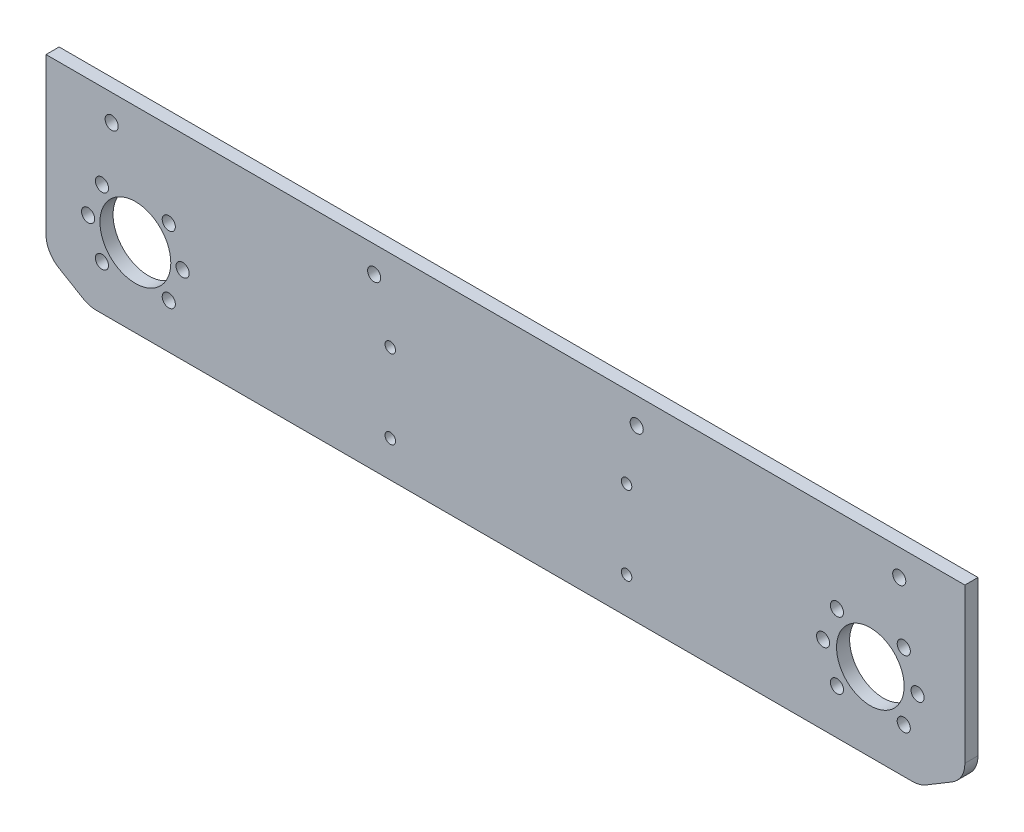
from build123d import *

# Parameters (mm, degrees)
SKETCH_1_R      = 2.5
SKETCH_1_R_2    = 12.875
SKETCH_1_R_3    = 13.5
SKETCH_1_R_4    = 2
EXTRUDE_1_DEPTH = 5


with BuildPart() as part:
    # 草圖1 → 填料-伸長1 (new body)
    with BuildSketch(Plane.XY):
        with BuildLine():
            Line((-177.402767175, 46.597232825), (172.597232825, 46.597232825))
            Line((172.597232825, 46.597232825), (172.597232825, -3.218275341))
            Line((172.597232825, -3.218275341), (172.597232825, -12.212255112))
            ThreePointArc((172.597232825, -12.212255112), (171.299816564, -17.138210478), (167.744225572, -20.785962926))
            Line((167.744225572, -20.785962926), (157.766802923, -26.775637768))
            ThreePointArc((157.766802923, -26.775637768), (155.290289709, -27.838762374), (152.619810177, -28.201929955))
            Line((152.619810177, -28.201929955), (-158.204749101, -28.201929955))
            ThreePointArc((-158.204749101, -28.201929955), (-160.839127997, -27.848693549), (-163.287395186, -26.813939522))
            Line((-163.287395186, -26.813939522), (-172.48541326, -21.385442237))
            ThreePointArc((-172.48541326, -21.385442237), (-176.08684631, -17.731937443), (-177.402767175, -12.77343267))
            Line((-177.402767175, -12.77343267), (-177.402767175, -10.307650594))
            Line((-177.402767175, -10.307650594), (-177.402767175, -3.218275341))
            Line((-177.402767175, -3.218275341), (-177.402767175, 46.597232825))
        make_face()
        with Locations((118.590211239, 1.636058568)):
            Circle(SKETCH_1_R, mode=Mode.SUBTRACT)
        with Locations((154.590211239, 1.636058568)):
            Circle(SKETCH_1_R, mode=Mode.SUBTRACT)
        with Locations((136.590211239, 1.636058568)):
            Circle(SKETCH_1_R_2, mode=Mode.SUBTRACT)
        with Locations((-143.364629919, 1.616144457)):
            Circle(SKETCH_1_R_3, mode=Mode.SUBTRACT)
        with Locations((-130.636707858, 14.344066518)):
            Circle(SKETCH_1_R, mode=Mode.SUBTRACT)
        with Locations((-156.09255198, 14.344066518)):
            Circle(SKETCH_1_R, mode=Mode.SUBTRACT)
        with Locations((-130.636707858, -11.111777604)):
            Circle(SKETCH_1_R, mode=Mode.SUBTRACT)
        with Locations((-156.09255198, -11.111777604)):
            Circle(SKETCH_1_R, mode=Mode.SUBTRACT)
        with Locations((-152.402767175, 36.597232825)):
            Circle(SKETCH_1_R, mode=Mode.SUBTRACT)
        with Locations((-52.402767175, 36.597232825)):
            Circle(SKETCH_1_R, mode=Mode.SUBTRACT)
        with Locations((47.597232825, 36.597232825)):
            Circle(SKETCH_1_R, mode=Mode.SUBTRACT)
        with Locations((147.597232825, 36.597232825)):
            Circle(SKETCH_1_R, mode=Mode.SUBTRACT)
        with Locations((-161.364629919, 1.616144457)):
            Circle(SKETCH_1_R, mode=Mode.SUBTRACT)
        with Locations((-125.364629919, 1.616144457)):
            Circle(SKETCH_1_R, mode=Mode.SUBTRACT)
        with Locations((149.318133301, -11.091863493)):
            Circle(SKETCH_1_R, mode=Mode.SUBTRACT)
        with Locations((123.862289178, -11.091863493)):
            Circle(SKETCH_1_R, mode=Mode.SUBTRACT)
        with Locations((123.862289178, 14.363980629)):
            Circle(SKETCH_1_R, mode=Mode.SUBTRACT)
        with Locations((149.318133301, 14.363980629)):
            Circle(SKETCH_1_R, mode=Mode.SUBTRACT)
        with Locations((-46.268993965, 15.590754881)):
            Circle(SKETCH_1_R_4, mode=Mode.SUBTRACT)
        with Locations((-46.268993965, -14.409245119)):
            Circle(SKETCH_1_R_4, mode=Mode.SUBTRACT)
        with Locations((43.737437285, 15.590754881)):
            Circle(SKETCH_1_R_4, mode=Mode.SUBTRACT)
        with Locations((43.737437285, -14.409245119)):
            Circle(SKETCH_1_R_4, mode=Mode.SUBTRACT)
    extrude(amount=EXTRUDE_1_DEPTH)


solid = part.part
